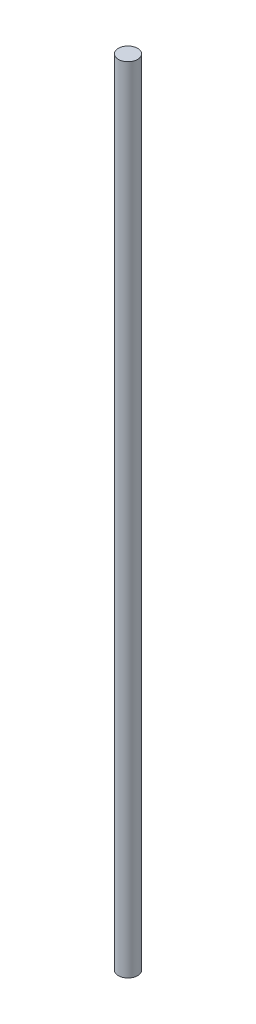
from build123d import *

# Parameters (mm, degrees)
SKETCH1_R           = 4
BOSS_EXTRUDE1_DEPTH = 330


with BuildPart() as part:
    # Sketch1 → Boss-Extrude1 (new body)
    with BuildSketch(Plane(origin=(0, 0, 0), x_dir=(1, 0, 0), z_dir=(0, 1, 0))):
        Circle(SKETCH1_R)
    extrude(amount=BOSS_EXTRUDE1_DEPTH)


solid = part.part
